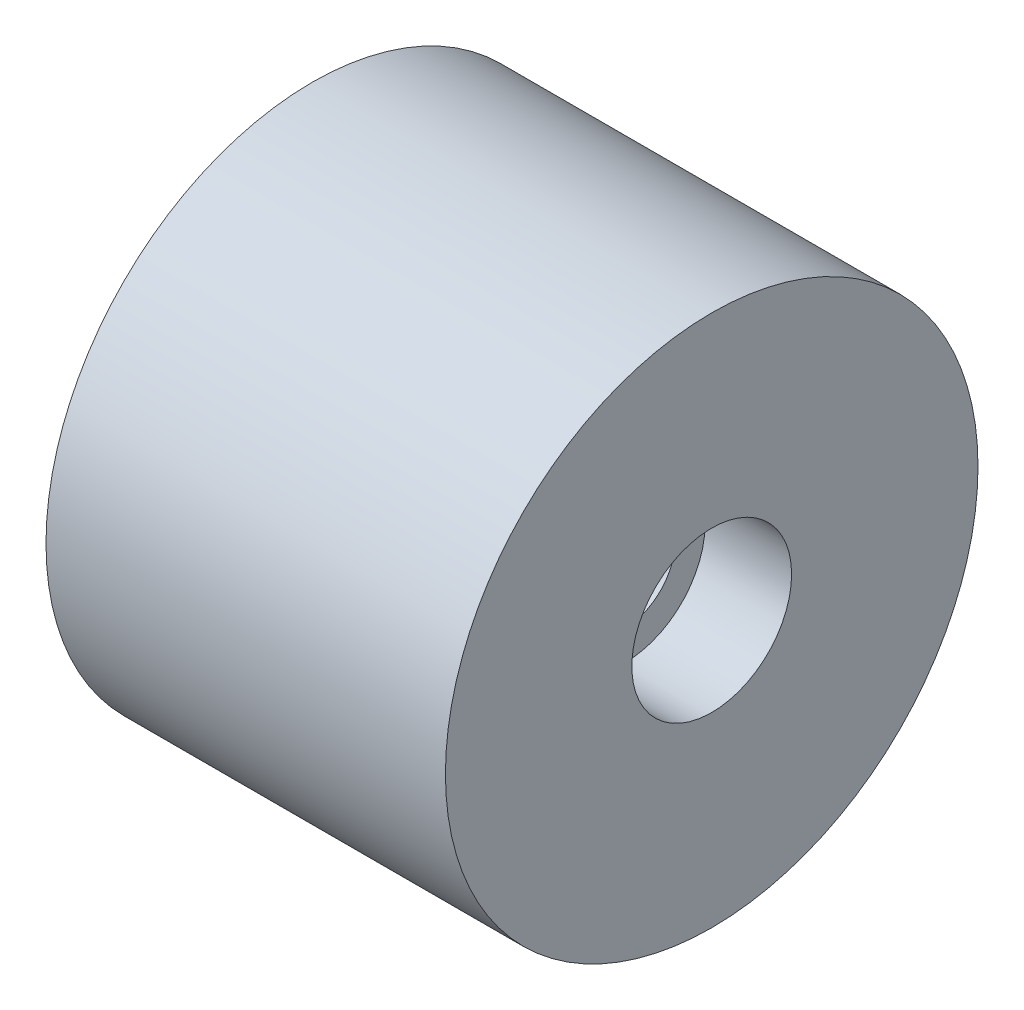
from build123d import *

# Parameters (mm, degrees)
SKETCH1_R           = 8
BOSS_EXTRUDE1_DEPTH = 12
CUT_EXTRUDE1_DEPTH  = 6
SKETCH3_R           = 2.4
CUT_EXTRUDE2_DEPTH  = 2.6
SKETCH4_R           = 1.5
CUT_EXTRUDE3_DEPTH  = 10.4
SKETCH5_R           = 3
CUT_EXTRUDE4_DEPTH  = 2


with BuildPart() as part:
    # Sketch1 → Boss-Extrude1 (new body)
    with BuildSketch(Plane(origin=(0, 0, 0), x_dir=(0, 0, -1), z_dir=(1, 0, 0))):
        Circle(SKETCH1_R)
    extrude(amount=BOSS_EXTRUDE1_DEPTH)

    # Sketch2 → Cut-Extrude1 (cut)
    with BuildSketch(Plane.ZY):
        Polygon((6.466323015, 0), (3.233161507, 5.6), (-3.233161507, 5.6), (-6.466323015, 0), (-3.233161507, -5.6), (3.233161507, -5.6), align=None)
    extrude(amount=-CUT_EXTRUDE1_DEPTH, mode=Mode.SUBTRACT)

    # Sketch3 → Cut-Extrude2 (cut)
    with BuildSketch(Plane(origin=(12, 0, 0), x_dir=(0, 0, -1), z_dir=(1, 0, 0))):
        Circle(SKETCH3_R)
    extrude(amount=-CUT_EXTRUDE2_DEPTH, mode=Mode.SUBTRACT)

    # Sketch4 → Cut-Extrude3 (cut, through all)
    with BuildSketch(Plane(origin=(9.4, 0, 0), x_dir=(0, 0, -1), z_dir=(1, 0, 0))):
        Circle(SKETCH4_R)
    extrude(amount=-CUT_EXTRUDE3_DEPTH, mode=Mode.SUBTRACT)

    # Sketch5 → Cut-Extrude4 (cut)
    with BuildSketch(Plane.ZY.offset(-6)):
        Circle(SKETCH5_R)
    extrude(amount=-CUT_EXTRUDE4_DEPTH, mode=Mode.SUBTRACT)


solid = part.part
